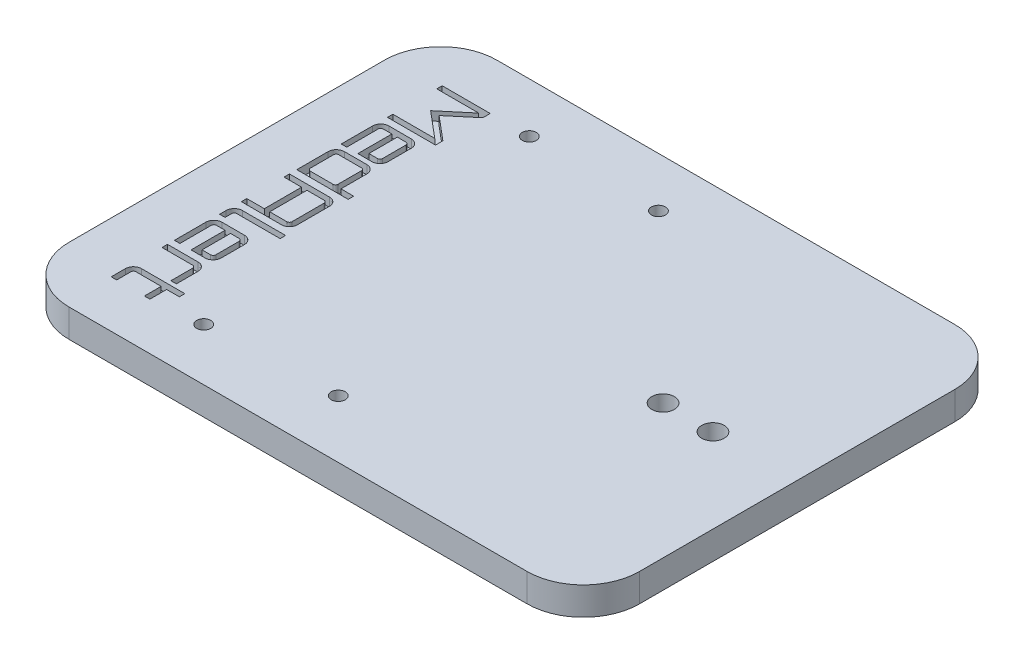
from build123d import *

# Parameters (mm, degrees)
SKETCH1_W           = 101.6
SKETCH1_H           = 76.2
BOSS_EXTRUDE1_DEPTH = 5
SKETCH2_R           = 2
CUT_EXTRUDE1_DEPTH  = 6
FILLET1_R           = 10
SKETCH4_R           = 1.25
CUT_EXTRUDE2_DEPTH  = 6
CUT_EXTRUDE3_DEPTH  = 1.5875


with BuildPart() as part:
    # Sketch1 → Boss-Extrude1 (new body)
    with BuildSketch(Plane(origin=(0, 0, 0), x_dir=(1, 0, 0), z_dir=(0, 1, 0))):
        Rectangle(SKETCH1_W, SKETCH1_H)
    extrude(amount=BOSS_EXTRUDE1_DEPTH)

    # Sketch2 → Cut-Extrude1 (cut, through all)
    with BuildSketch(Plane(origin=(0, 5, 0), x_dir=(1, 0, 0), z_dir=(0, 1, 0))):
        with Locations((35.8, 0)):
            Circle(SKETCH2_R)
        with Locations((26.91, 0)):
            Circle(SKETCH2_R)
    extrude(amount=-CUT_EXTRUDE1_DEPTH, mode=Mode.SUBTRACT)

    # Fillet1
    fillet1_edges = [part.edges().sort_by_distance(p)[0] for p in [
        (-50.8, 2.5, -38.1),
        (50.8, 2.5, -38.1),
        (50.8, 2.5, 38.1),
        (-50.8, 2.5, 38.1),
    ]]
    fillet(fillet1_edges, radius=FILLET1_R)

    # Sketch4 → Cut-Extrude2 (cut, through all)
    with BuildSketch(Plane(origin=(0, 5, 0), x_dir=(1, 0, 0), z_dir=(0, 1, 0))):
        with Locations((-3.134370543, 29.218470634)):
            Circle(SKETCH4_R)
        with Locations((-3.134370543, -27.818050268)):
            Circle(SKETCH4_R)
        with Locations((-26.134370543, 29.218470634)):
            Circle(SKETCH4_R)
        with Locations((-26.134370543, -28.781529366)):
            Circle(SKETCH4_R)
    extrude(amount=-CUT_EXTRUDE2_DEPTH, mode=Mode.SUBTRACT)

    # Sketch5 → Cut-Extrude3 (cut)
    with BuildSketch(Plane(origin=(0, 5, 0), x_dir=(1, 0, 0), z_dir=(0, 1, 0))):
        Polygon((-41.714230592, 29.273931244), (-33.154430592, 29.273931244), (-33.154430592, 27.954789873), (-37.387034128, 24.399815672), (-33.154430592, 20.844841471), (-33.154430592, 19.5257001), (-41.714230592, 19.5257001), (-41.714230592, 20.488828089), (-34.248268808, 20.488828089), (-38.897081225, 24.399815672), (-34.248268808, 28.310803255), (-41.714230592, 28.310803255), align=None)
        with BuildLine():
            add(Edge.make_bspline(
                [(-41.714230592, 16.88741736), (-41.712202655, 16.951845546), (-41.708200637, 17.078990853), (-41.667763496, 17.264233296), (-41.608496053, 17.442088744), (-41.52139129, 17.608473), (-41.414767915, 17.762425862), (-41.292564206, 17.903570415), (-41.151417443, 18.025730049), (-40.997518132, 18.132534349), (-40.830272787, 18.219298696), (-40.653091122, 18.280949464), (-40.467195446, 18.318702486), (-40.340805862, 18.323026855), (-40.276418095, 18.325229857)],
                knots=[0, 0, 0, 0, 0.000193001, 0.000380877, 0.000566344, 0.000754031, 0.000941994, 0.001127245, 0.001312497, 0.001500459, 0.001688146, 0.001875801, 0.002061651, 0.002254653, 0.002254653, 0.002254653, 0.002254653], degree=3))
            Line((-40.276418095, 18.325229857), (-36.257078613, 18.325229857))
            add(Edge.make_bspline(
                [(-36.257078613, 18.325229857), (-36.192706319, 18.322959997), (-36.065784313, 18.318484544), (-35.879657952, 18.281552513), (-35.702807278, 18.218849465), (-35.535960075, 18.132588362), (-35.382087657, 18.025714688), (-35.240917391, 17.903578582), (-35.118781285, 17.762408315), (-35.011907611, 17.608535898), (-34.925646508, 17.441688695), (-34.86294346, 17.264838021), (-34.826011429, 17.07871166), (-34.821535976, 16.951789654), (-34.819266116, 16.88741736)],
                knots=[0, 0, 0, 0, 0.000193001, 0.000380538, 0.000566571, 0.000754258, 0.00094222, 0.001127472, 0.001312724, 0.001500686, 0.001688373, 0.001874405, 0.002061942, 0.002254944, 0.002254944, 0.002254944, 0.002254944], degree=3))
            Line((-34.819266116, 16.88741736), (-34.819266116, 12.751126622))
            add(Edge.make_bspline(
                [(-34.819266116, 12.751126622), (-34.821521309, 12.685040069), (-34.82594932, 12.555280884), (-34.862649634, 12.365647072), (-34.925705942, 12.186615779), (-35.011438059, 12.018310325), (-35.118745743, 11.864021942), (-35.241478514, 11.723008847), (-35.381455096, 11.598889002), (-35.536104242, 11.492487156), (-35.702385771, 11.405265217), (-35.880268447, 11.346028832), (-36.065503623, 11.305583401), (-36.192649924, 11.301582517), (-36.257078613, 11.299555154)],
                knots=[0, 0, 0, 0, 0.000198151, 0.000389065, 0.00057672, 0.000765937, 0.000953899, 0.001139151, 0.001325541, 0.001513504, 0.00170119, 0.001886658, 0.002074533, 0.002267535, 0.002267535, 0.002267535, 0.002267535], degree=3))
            Line((-36.257078613, 11.299555154), (-38.754331898, 11.299555154))
            Line((-38.754331898, 11.299555154), (-38.754331898, 17.35178264))
            Line((-38.754331898, 17.35178264), (-40.276418095, 17.35178264))
            add(Edge.make_bspline(
                [(-40.276418095, 17.35178264), (-40.307010937, 17.350242158), (-40.367052556, 17.347218801), (-40.453565175, 17.319680396), (-40.533952598, 17.276341642), (-40.604277118, 17.216012784), (-40.666133623, 17.146922482), (-40.706521439, 17.06573996), (-40.734815441, 16.979296148), (-40.737621004, 16.918616327), (-40.739063504, 16.88741736)],
                knots=[0, 0, 0, 0, 9.1558e-05, 0.000179692, 0.000269735, 0.000363763, 0.000456477, 0.000545712, 0.000633846, 0.000727116, 0.000727116, 0.000727116, 0.000727116], degree=3))
            Line((-40.739063504, 16.88741736), (-40.739063504, 11.299555154))
            Line((-40.739063504, 11.299555154), (-41.714230592, 11.299555154))
            Line((-41.714230592, 11.299555154), (-41.714230592, 16.88741736))
        make_face()
        with BuildLine():
            Line((-37.77916481, 17.35178264), (-37.77916481, 12.286761342))
            Line((-37.77916481, 12.286761342), (-36.257078613, 12.286761342))
            add(Edge.make_bspline(
                [(-36.257078613, 12.286761342), (-36.226460685, 12.288256003), (-36.166369832, 12.291189431), (-36.080476665, 12.319303136), (-35.999293132, 12.359691309), (-35.930203168, 12.421547662), (-35.86987401, 12.491872421), (-35.826536074, 12.572259078), (-35.798819889, 12.659323725), (-35.795922776, 12.719953426), (-35.794433204, 12.751126622)],
                knots=[0, 0, 0, 0, 9.1558e-05, 0.000179692, 0.000268927, 0.00036164, 0.000455669, 0.000545712, 0.000633846, 0.000727116, 0.000727116, 0.000727116, 0.000727116], degree=3))
            Line((-35.794433204, 12.751126622), (-35.794433204, 16.88741736))
            add(Edge.make_bspline(
                [(-35.794433204, 16.88741736), (-35.795915847, 16.918595875), (-35.798799485, 16.97923592), (-35.826613164, 17.06622573), (-35.869364321, 17.146513878), (-35.93074951, 17.215466425), (-35.999701779, 17.276851352), (-36.079990749, 17.319603254), (-36.166428813, 17.347238783), (-36.226480594, 17.350248902), (-36.257078613, 17.35178264)],
                knots=[0, 0, 0, 0, 9.327e-05, 0.000181404, 0.000271447, 0.000364161, 0.000456875, 0.000546918, 0.000635052, 0.00072661, 0.00072661, 0.00072661, 0.00072661], degree=3))
            Line((-36.257078613, 17.35178264), (-37.77916481, 17.35178264))
        make_face(mode=Mode.SUBTRACT)
        with BuildLine():
            add(Edge.make_bspline(
                [(-41.714230592, 8.953650553), (-41.712221556, 9.01979301), (-41.708273492, 9.149773058), (-41.668055971, 9.338533495), (-41.608429869, 9.518550156), (-41.521887325, 9.686433191), (-41.414713989, 9.840669776), (-41.29257856, 9.981850261), (-41.151413534, 10.104000284), (-40.997519184, 10.210807195), (-40.830272505, 10.29757084), (-40.653091196, 10.359221796), (-40.467195426, 10.396974768), (-40.340805856, 10.401299144), (-40.276418095, 10.40350215)],
                knots=[0, 0, 0, 0, 0.000198151, 0.000389398, 0.000576492, 0.00076571, 0.000953672, 0.001138924, 0.001324175, 0.001512138, 0.001699825, 0.00188748, 0.002073329, 0.002266331, 0.002266331, 0.002266331, 0.002266331], degree=3))
            Line((-40.276418095, 10.40350215), (-36.257078613, 10.40350215))
            add(Edge.make_bspline(
                [(-36.257078613, 10.40350215), (-36.192706325, 10.401232286), (-36.065784332, 10.396756826), (-35.879657879, 10.359824844), (-35.702807552, 10.297121613), (-35.535959038, 10.2108612), (-35.382091508, 10.103984953), (-35.240903252, 9.981858317), (-35.118834402, 9.840652647), (-35.011413975, 9.686494718), (-34.925712347, 9.518153985), (-34.862647901, 9.339132108), (-34.825949776, 9.149495764), (-34.821521462, 9.019736928), (-34.819266116, 8.953650553)],
                knots=[0, 0, 0, 0, 0.000193001, 0.000380538, 0.000566571, 0.000754258, 0.00094222, 0.001127472, 0.001312724, 0.001500686, 0.001689903, 0.001877558, 0.002068472, 0.002266623, 0.002266623, 0.002266623, 0.002266623], degree=3))
            Line((-34.819266116, 8.953650553), (-34.819266116, 4.352994535))
            Line((-34.819266116, 4.352994535), (-32.561074956, 4.352994535))
            Line((-32.561074956, 4.352994535), (-32.561074956, 3.377827446))
            Line((-32.561074956, 3.377827446), (-41.714230592, 3.377827446))
            Line((-41.714230592, 3.377827446), (-41.714230592, 8.953650553))
        make_face()
        with BuildLine():
            Line((-40.739063504, 8.953650553), (-40.739063504, 4.815639944))
            add(Edge.make_bspline(
                [(-40.739063504, 4.815639944), (-40.737562032, 4.785027226), (-40.73461524, 4.724946599), (-40.706599302, 4.638978628), (-40.665634815, 4.557690432), (-40.604831642, 4.487226397), (-40.534367606, 4.426423223), (-40.45307941, 4.385458736), (-40.36711144, 4.357442799), (-40.307030812, 4.354496006), (-40.276418095, 4.352994535)],
                knots=[0, 0, 0, 0, 9.1558e-05, 0.000179692, 0.000268927, 0.000362955, 0.000456983, 0.000546218, 0.000634352, 0.00072591, 0.00072591, 0.00072591, 0.00072591], degree=3))
            Line((-40.276418095, 4.352994535), (-36.257078613, 4.352994535))
            add(Edge.make_bspline(
                [(-36.257078613, 4.352994535), (-36.226460685, 4.354489196), (-36.166369833, 4.357422623), (-36.080476661, 4.385536332), (-35.999293144, 4.42592449), (-35.930203121, 4.487780899), (-35.869874187, 4.558105446), (-35.826535452, 4.638492862), (-35.798997042, 4.725005483), (-35.795973686, 4.785047102), (-35.794433204, 4.815639944)],
                knots=[0, 0, 0, 0, 9.1558e-05, 0.000179692, 0.000268927, 0.00036164, 0.000455669, 0.000545712, 0.000633846, 0.000725404, 0.000725404, 0.000725404, 0.000725404], degree=3))
            Line((-35.794433204, 4.815639944), (-35.794433204, 8.953650553))
            add(Edge.make_bspline(
                [(-35.794433204, 8.953650553), (-35.795966942, 8.984248572), (-35.79897706, 9.044300352), (-35.826612593, 9.13073842), (-35.86936448, 9.211027375), (-35.930749467, 9.279979698), (-35.99970179, 9.341364685), (-36.079990746, 9.384116572), (-36.166428814, 9.411752105), (-36.226480594, 9.414762224), (-36.257078613, 9.416295961)],
                knots=[0, 0, 0, 0, 9.1558e-05, 0.000179692, 0.000269735, 0.000362449, 0.000455162, 0.000545205, 0.000633339, 0.000724897, 0.000724897, 0.000724897, 0.000724897], degree=3))
            Line((-36.257078613, 9.416295961), (-40.276418095, 9.416295961))
            add(Edge.make_bspline(
                [(-40.276418095, 9.416295961), (-40.307010937, 9.414755479), (-40.367052555, 9.411732123), (-40.453565176, 9.384193713), (-40.533952592, 9.340854979), (-40.604277139, 9.280526045), (-40.666133548, 9.211436022), (-40.706521706, 9.130252504), (-40.734635416, 9.044359333), (-40.737568843, 8.98426848), (-40.739063504, 8.953650553)],
                knots=[0, 0, 0, 0, 9.1558e-05, 0.000179692, 0.000269735, 0.000363763, 0.000456477, 0.000545712, 0.000633846, 0.000725404, 0.000725404, 0.000725404, 0.000725404], degree=3))
        make_face(mode=Mode.SUBTRACT)
        with BuildLine():
            Line((-41.714230592, 2.062125819), (-34.581923861, 2.062125819))
            add(Edge.make_bspline(
                [(-34.581923861, 2.062125819), (-34.51752073, 2.059946903), (-34.390537922, 2.055650763), (-34.205222364, 2.017481893), (-34.02728682, 1.959965884), (-33.861510954, 1.874236203), (-33.706472823, 1.771489086), (-33.56610203, 1.651106405), (-33.44456763, 1.511647623), (-33.34239086, 1.356709591), (-33.2565718, 1.191004236), (-33.199079563, 1.013049938), (-33.160904336, 0.827739395), (-33.156609066, 0.700755901), (-33.154430592, 0.636352421)],
                knots=[0, 0, 0, 0, 0.000193001, 0.000380538, 0.000565455, 0.00075236, 0.000938392, 0.001122515, 0.00130534, 0.001491372, 0.001678277, 0.001863193, 0.00205073, 0.002243732, 0.002243732, 0.002243732, 0.002243732], degree=3))
            Line((-33.154430592, 0.636352421), (-33.154430592, -5.070180912))
            add(Edge.make_bspline(
                [(-33.154430592, -5.070180912), (-33.156542973, -5.134599385), (-33.160689459, -5.261049242), (-33.199666595, -5.446142016), (-33.256124602, -5.624412971), (-33.342465046, -5.790495654), (-33.44446762, -5.945579567), (-33.566673078, -6.084852617), (-33.705852561, -6.207178855), (-33.861593547, -6.309690188), (-34.027264928, -6.395539262), (-34.205228262, -6.453023516), (-34.390536388, -6.491200878), (-34.517520214, -6.495495855), (-34.581923861, -6.497674181)],
                knots=[0, 0, 0, 0, 0.000193001, 0.000378851, 0.0005654, 0.000752305, 0.000938337, 0.001121162, 0.001306414, 0.001492446, 0.001679351, 0.001864268, 0.002051804, 0.002244806, 0.002244806, 0.002244806, 0.002244806], degree=3))
            Line((-34.581923861, -6.497674181), (-41.714230592, -6.497674181))
            Line((-41.714230592, -6.497674181), (-41.714230592, -5.534546192))
            Line((-41.714230592, -5.534546192), (-38.587504372, -5.534546192))
            Line((-38.587504372, -5.534546192), (-38.587504372, 1.09899783))
            Line((-38.587504372, 1.09899783), (-41.714230592, 1.09899783))
            Line((-41.714230592, 1.09899783), (-41.714230592, 2.062125819))
        make_face()
        with BuildLine():
            Line((-37.624376383, 1.09899783), (-37.624376383, -5.534546192))
            Line((-37.624376383, -5.534546192), (-34.581923861, -5.534546192))
            add(Edge.make_bspline(
                [(-34.581923861, -5.534546192), (-34.550724894, -5.533103692), (-34.490045072, -5.530298129), (-34.403601265, -5.502004131), (-34.322418726, -5.461616301), (-34.253328485, -5.399759852), (-34.192999403, -5.329435119), (-34.149661447, -5.249048455), (-34.121945267, -5.16198381), (-34.119048153, -5.101354109), (-34.117558581, -5.070180912)],
                knots=[0, 0, 0, 0, 9.327e-05, 0.000181404, 0.000270639, 0.000363353, 0.000457381, 0.000547424, 0.000635558, 0.000728828, 0.000728828, 0.000728828, 0.000728828], degree=3))
            Line((-34.117558581, -5.070180912), (-34.117558581, 0.636352421))
            add(Edge.make_bspline(
                [(-34.117558581, 0.636352421), (-34.119092319, 0.666950441), (-34.122102438, 0.727002221), (-34.149737967, 0.813440285), (-34.19248987, 0.893729255), (-34.253874796, 0.962681524), (-34.322827343, 1.024066713), (-34.403115491, 1.066817871), (-34.490105301, 1.09463155), (-34.550745346, 1.097515187), (-34.581923861, 1.09899783)],
                knots=[0, 0, 0, 0, 9.1558e-05, 0.000179692, 0.000269735, 0.000362449, 0.000455162, 0.000545205, 0.000633339, 0.00072661, 0.00072661, 0.00072661, 0.00072661], degree=3))
            Line((-34.581923861, 1.09899783), (-37.624376383, 1.09899783))
        make_face(mode=Mode.SUBTRACT)
        with BuildLine():
            add(Edge.make_bspline(
                [(-41.714230592, -9.211631264), (-41.712202655, -9.147203077), (-41.708200638, -9.020057766), (-41.667763493, -8.834815343), (-41.608496065, -8.656959821), (-41.521391245, -8.490575847), (-41.414768084, -8.336621932), (-41.292563588, -8.195481255), (-41.151419768, -8.073307131), (-40.997509321, -7.966557653), (-40.830305598, -7.879588389), (-40.652861155, -7.818662383), (-40.467427317, -7.778051189), (-40.340845602, -7.774106607), (-40.276418095, -7.772098895)],
                knots=[0, 0, 0, 0, 0.000193001, 0.000380877, 0.000566344, 0.000754031, 0.000941994, 0.001127245, 0.001312497, 0.001500459, 0.001688146, 0.001875801, 0.002061993, 0.002254994, 0.002254994, 0.002254994, 0.002254994], degree=3))
            Line((-40.276418095, -7.772098895), (-32.561074956, -7.772098895))
            Line((-32.561074956, -7.772098895), (-32.561074956, -8.747265984))
            Line((-32.561074956, -8.747265984), (-40.276418095, -8.747265984))
            add(Edge.make_bspline(
                [(-40.276418095, -8.747265984), (-40.307010937, -8.748806466), (-40.367052556, -8.751829823), (-40.453565175, -8.779368228), (-40.533952598, -8.822706982), (-40.604277118, -8.88303584), (-40.666133623, -8.952126141), (-40.706521439, -9.033308664), (-40.734815441, -9.119752476), (-40.737621004, -9.180432297), (-40.739063504, -9.211631264)],
                knots=[0, 0, 0, 0, 9.1558e-05, 0.000179692, 0.000269735, 0.000363763, 0.000456477, 0.000545712, 0.000633846, 0.000727116, 0.000727116, 0.000727116, 0.000727116], degree=3))
            Line((-40.739063504, -9.211631264), (-40.739063504, -10.375984207))
            Line((-40.739063504, -10.375984207), (-41.714230592, -10.375984207))
            Line((-41.714230592, -10.375984207), (-41.714230592, -9.211631264))
        make_face()
        with BuildLine():
            add(Edge.make_bspline(
                [(-41.714230592, -12.831960579), (-41.712202655, -12.767532393), (-41.708200637, -12.640387085), (-41.667763496, -12.455144642), (-41.608496053, -12.277289195), (-41.52139129, -12.110904939), (-41.414767915, -11.956952076), (-41.292564206, -11.815807523), (-41.151417443, -11.69364789), (-40.997518132, -11.586843589), (-40.830272787, -11.500079243), (-40.653091122, -11.438428474), (-40.467195446, -11.400675453), (-40.340805862, -11.396351083), (-40.276418095, -11.394148081)],
                knots=[0, 0, 0, 0, 0.000193001, 0.000380877, 0.000566344, 0.000754031, 0.000941994, 0.001127245, 0.001312497, 0.001500459, 0.001688146, 0.001875801, 0.002061651, 0.002254653, 0.002254653, 0.002254653, 0.002254653], degree=3))
            Line((-40.276418095, -11.394148081), (-36.257078613, -11.394148081))
            add(Edge.make_bspline(
                [(-36.257078613, -11.394148081), (-36.192706319, -11.396417941), (-36.065784313, -11.400893395), (-35.879657952, -11.437825425), (-35.702807278, -11.500528474), (-35.535960075, -11.586789577), (-35.382087657, -11.693663251), (-35.240917391, -11.815799356), (-35.118781285, -11.956969623), (-35.011907611, -12.110842041), (-34.925646508, -12.277689243), (-34.86294346, -12.454539918), (-34.826011429, -12.640666278), (-34.821535976, -12.767588284), (-34.819266116, -12.831960579)],
                knots=[0, 0, 0, 0, 0.000193001, 0.000380538, 0.000566571, 0.000754258, 0.00094222, 0.001127472, 0.001312724, 0.001500686, 0.001688373, 0.001874405, 0.002061942, 0.002254944, 0.002254944, 0.002254944, 0.002254944], degree=3))
            Line((-34.819266116, -12.831960579), (-34.819266116, -16.968251316))
            add(Edge.make_bspline(
                [(-34.819266116, -16.968251316), (-34.821521309, -17.03433787), (-34.82594932, -17.164097055), (-34.862649634, -17.353730866), (-34.925705942, -17.53276216), (-35.011438059, -17.701067614), (-35.118745743, -17.855355997), (-35.241478514, -17.996369092), (-35.381455096, -18.120488937), (-35.536104242, -18.226890783), (-35.702385771, -18.314112722), (-35.880268447, -18.373349106), (-36.065503623, -18.413794537), (-36.192649924, -18.417795422), (-36.257078613, -18.419822785)],
                knots=[0, 0, 0, 0, 0.000198151, 0.000389065, 0.00057672, 0.000765937, 0.000953899, 0.001139151, 0.001325541, 0.001513504, 0.00170119, 0.001886658, 0.002074533, 0.002267535, 0.002267535, 0.002267535, 0.002267535], degree=3))
            Line((-36.257078613, -18.419822785), (-38.754331898, -18.419822785))
            Line((-38.754331898, -18.419822785), (-38.754331898, -12.367595298))
            Line((-38.754331898, -12.367595298), (-40.276418095, -12.367595298))
            add(Edge.make_bspline(
                [(-40.276418095, -12.367595298), (-40.307010937, -12.369135781), (-40.367052556, -12.372159138), (-40.453565175, -12.399697543), (-40.533952598, -12.443036297), (-40.604277118, -12.503365155), (-40.666133623, -12.572455456), (-40.706521439, -12.653637979), (-40.734815441, -12.740081791), (-40.737621004, -12.800761612), (-40.739063504, -12.831960579)],
                knots=[0, 0, 0, 0, 9.1558e-05, 0.000179692, 0.000269735, 0.000363763, 0.000456477, 0.000545712, 0.000633846, 0.000727116, 0.000727116, 0.000727116, 0.000727116], degree=3))
            Line((-40.739063504, -12.831960579), (-40.739063504, -18.419822785))
            Line((-40.739063504, -18.419822785), (-41.714230592, -18.419822785))
            Line((-41.714230592, -18.419822785), (-41.714230592, -12.831960579))
        make_face()
        with BuildLine():
            Line((-37.77916481, -12.367595298), (-37.77916481, -17.432616596))
            Line((-37.77916481, -17.432616596), (-36.257078613, -17.432616596))
            add(Edge.make_bspline(
                [(-36.257078613, -17.432616596), (-36.226460685, -17.431121935), (-36.166369832, -17.428188508), (-36.080476665, -17.400074802), (-35.999293132, -17.35968663), (-35.930203168, -17.297830277), (-35.86987401, -17.227505517), (-35.826536074, -17.14711886), (-35.798819889, -17.060054213), (-35.795922776, -16.999424513), (-35.794433204, -16.968251316)],
                knots=[0, 0, 0, 0, 9.1558e-05, 0.000179692, 0.000268927, 0.00036164, 0.000455669, 0.000545712, 0.000633846, 0.000727116, 0.000727116, 0.000727116, 0.000727116], degree=3))
            Line((-35.794433204, -16.968251316), (-35.794433204, -12.831960579))
            add(Edge.make_bspline(
                [(-35.794433204, -12.831960579), (-35.795915847, -12.800782063), (-35.798799485, -12.740142019), (-35.826613164, -12.653152209), (-35.869364321, -12.572864061), (-35.93074951, -12.503911513), (-35.999701779, -12.442526587), (-36.079990749, -12.399774684), (-36.166428813, -12.372139155), (-36.226480594, -12.369129036), (-36.257078613, -12.367595298)],
                knots=[0, 0, 0, 0, 9.327e-05, 0.000181404, 0.000271447, 0.000364161, 0.000456875, 0.000546918, 0.000635052, 0.00072661, 0.00072661, 0.00072661, 0.00072661], degree=3))
            Line((-36.257078613, -12.367595298), (-37.77916481, -12.367595298))
        make_face(mode=Mode.SUBTRACT)
        with BuildLine():
            Line((-41.714230592, -19.65985007), (-36.257078613, -19.65985007))
            add(Edge.make_bspline(
                [(-36.257078613, -19.65985007), (-36.192667344, -19.661926575), (-36.06555542, -19.666024437), (-35.879883583, -19.705800019), (-35.702775245, -19.767791189), (-35.535968708, -19.85425433), (-35.38208538, -19.961073796), (-35.240917997, -20.083224229), (-35.11878112, -20.224390663), (-35.011907656, -20.378264122), (-34.925646497, -20.545111045), (-34.862943463, -20.721961794), (-34.826011428, -20.908088135), (-34.821535975, -21.035010144), (-34.819266116, -21.099382439)],
                knots=[0, 0, 0, 0, 0.000193001, 0.000380877, 0.00056691, 0.000754597, 0.000942559, 0.001127811, 0.001313062, 0.001501025, 0.001688712, 0.001874744, 0.002062281, 0.002255283, 0.002255283, 0.002255283, 0.002255283], degree=3))
            Line((-34.819266116, -21.099382439), (-34.819266116, -24.974252723))
            Line((-34.819266116, -24.974252723), (-35.794433204, -24.974252723))
            Line((-35.794433204, -24.974252723), (-35.794433204, -21.099382439))
            add(Edge.make_bspline(
                [(-35.794433204, -21.099382439), (-35.795915847, -21.068203924), (-35.798799485, -21.007563879), (-35.826613164, -20.920574069), (-35.869364321, -20.840285921), (-35.93074951, -20.771333374), (-35.999701779, -20.709948448), (-36.079990749, -20.667196545), (-36.166428813, -20.639561016), (-36.226480594, -20.636550897), (-36.257078613, -20.635017159)],
                knots=[0, 0, 0, 0, 9.327e-05, 0.000181404, 0.000271447, 0.000364161, 0.000456875, 0.000546918, 0.000635052, 0.00072661, 0.00072661, 0.00072661, 0.00072661], degree=3))
            Line((-36.257078613, -20.635017159), (-41.714230592, -20.635017159))
            Line((-41.714230592, -20.635017159), (-41.714230592, -19.65985007))
        make_face()
        with BuildLine():
            add(Edge.make_bspline(
                [(-41.714230592, -27.165368897), (-41.7122222, -27.09922583), (-41.708275402, -26.969244586), (-41.668048707, -26.780492821), (-41.608456607, -26.60044402), (-41.521786444, -26.432681614), (-41.415330022, -26.278353422), (-41.291807291, -26.139086937), (-41.15253295, -26.016271338), (-40.996722321, -25.91388384), (-40.83065297, -25.827527094), (-40.652378452, -25.771073443), (-40.467286619, -25.732095156), (-40.340836633, -25.727948829), (-40.276418095, -25.725836528)],
                knots=[0, 0, 0, 0, 0.000198151, 0.000389398, 0.000576492, 0.00076571, 0.000953672, 0.001137634, 0.001322886, 0.001508918, 0.001695823, 0.001882372, 0.002068221, 0.002261223, 0.002261223, 0.002261223, 0.002261223], degree=3))
            Line((-40.276418095, -25.725836528), (-32.561074956, -25.725836528))
            Line((-32.561074956, -25.725836528), (-32.561074956, -26.701003617))
            Line((-32.561074956, -26.701003617), (-34.819266116, -26.701003617))
            Line((-34.819266116, -26.701003617), (-34.819266116, -29.68498051))
            Line((-34.819266116, -29.68498051), (-35.794433204, -29.68498051))
            Line((-35.794433204, -29.68498051), (-35.794433204, -26.701003617))
            Line((-35.794433204, -26.701003617), (-40.276418095, -26.701003617))
            add(Edge.make_bspline(
                [(-40.276418095, -26.701003617), (-40.307010937, -26.702544099), (-40.367052556, -26.705567456), (-40.453565175, -26.733105861), (-40.533952598, -26.776444615), (-40.604277118, -26.836773473), (-40.666133623, -26.905863774), (-40.706521439, -26.987046297), (-40.734815441, -27.073490109), (-40.737621004, -27.13416993), (-40.739063504, -27.165368897)],
                knots=[0, 0, 0, 0, 9.1558e-05, 0.000179692, 0.000269735, 0.000363763, 0.000456477, 0.000545712, 0.000633846, 0.000727116, 0.000727116, 0.000727116, 0.000727116], degree=3))
            Line((-40.739063504, -27.165368897), (-40.739063504, -29.68498051))
            Line((-40.739063504, -29.68498051), (-41.714230592, -29.68498051))
            Line((-41.714230592, -29.68498051), (-41.714230592, -27.165368897))
        make_face()
    extrude(amount=-CUT_EXTRUDE3_DEPTH, mode=Mode.SUBTRACT)


solid = part.part
